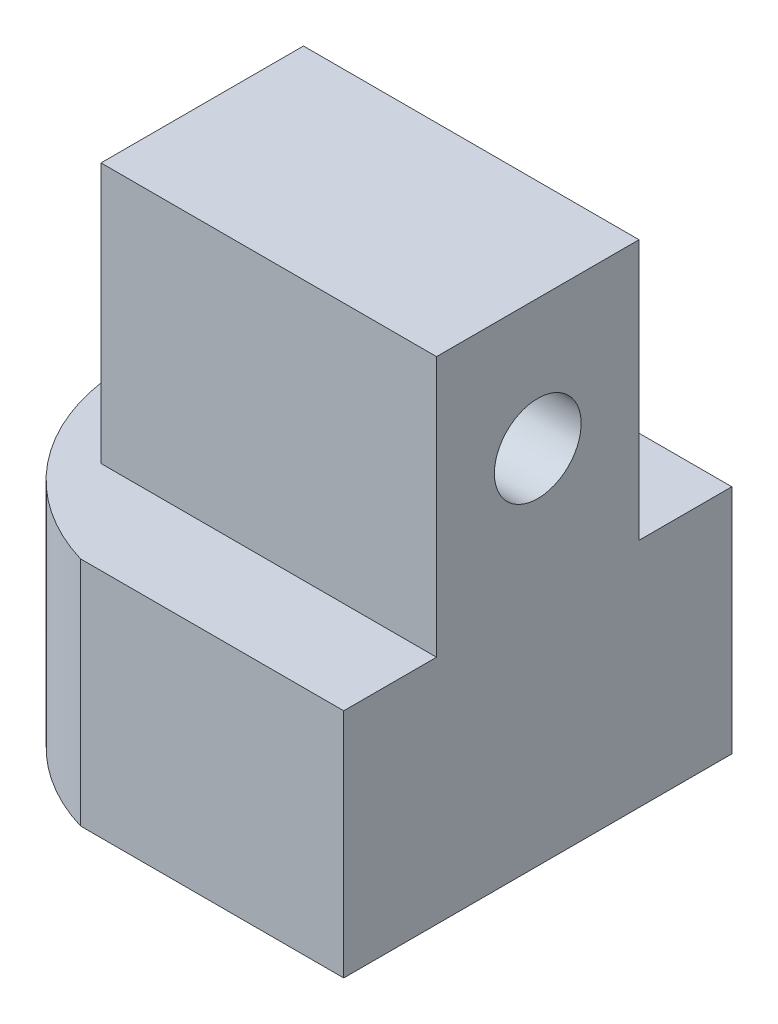
from build123d import *

# Parameters (mm, degrees)
SKETCH1_R           = 7
SKETCH1_R_2         = 4
BOSS_EXTRUDE1_DEPTH = 6
SKETCH2_R           = 7
BOSS_EXTRUDE2_DEPTH = 10
CUT_EXTRUDE1_DEPTH  = 8
SKETCH4_W           = 4.3
SKETCH4_H           = 6.3
CUT_EXTRUDE2_DEPTH  = 6
SKETCH5_OUTSIDE_W   = 21.092
SKETCH5_OUTSIDE_H   = 21.092
CUT_EXTRUDE3_DEPTH  = 8
BOSS_EXTRUDE3_DEPTH = 8
SKETCH9_R           = 7
CUT_EXTRUDE6_DEPTH  = 8
SKETCH10_W          = 9
SKETCH10_H          = 7
BOSS_EXTRUDE5_DEPTH = 9
SKETCH11_W          = 5.3
SKETCH11_H          = 5.3
CUT_EXTRUDE7_DEPTH  = 6
BOSS_EXTRUDE6_DEPTH = 8
SKETCH14_W          = 7
SKETCH14_H          = 9
BOSS_EXTRUDE7_DEPTH = 2.6
SKETCH15_W          = 4
SKETCH15_H          = 5
CUT_EXTRUDE10_DEPTH = 9
SKETCH16_R          = 1.5
CUT_EXTRUDE11_DEPTH = 6.6


with BuildPart() as part:
    # Sketch1 → Boss-Extrude1 (new body)
    with BuildSketch(Plane(origin=(0, 0, 0), x_dir=(1, 0, 0), z_dir=(0, 1, 0))):
        with Locations(Location((0, 0, 0), (0, 0, 270))):  # turned: the seam where the file's is
            Circle(SKETCH1_R)
        with Locations(Location((0, 0, 0), (0, 0, 270))):  # turned: the seam where the file's is
            Circle(SKETCH1_R_2, mode=Mode.SUBTRACT)
    extrude(amount=BOSS_EXTRUDE1_DEPTH)

    # Sketch2 → Boss-Extrude2 (add)
    with BuildSketch(Plane(origin=(0, 6, 0), x_dir=(1, 0, 0), z_dir=(0, 1, 0))):
        with Locations(Location((0, 0, 0), (0, 0, 270))):  # turned: the seam where the file's is
            Circle(SKETCH2_R)
    extrude(amount=BOSS_EXTRUDE2_DEPTH)

    # Sketch3 → Cut-Extrude1 (cut)
    with BuildSketch(Plane(origin=(0, 16, 0), x_dir=(1, 0, 0), z_dir=(0, 1, 0))):
        with BuildLine():
            Line((0, 7), (0, -7))
            ThreePointArc((0, -7), (-7, 0), (0, 7))
        make_face()
    extrude(amount=-CUT_EXTRUDE1_DEPTH, mode=Mode.SUBTRACT)

    # Sketch4 → Cut-Extrude2 (cut)
    with BuildSketch(Plane.ZY):
        with Locations((0, 12.15)):
            Rectangle(SKETCH4_W, SKETCH4_H)
    extrude(amount=-CUT_EXTRUDE2_DEPTH, mode=Mode.SUBTRACT)

    # Sketch5 outside → Cut-Extrude3 (cut)
    with BuildSketch(Plane(origin=(0, 16, 0), x_dir=(1, 0, 0), z_dir=(0, 1, 0))):
        Rectangle(SKETCH5_OUTSIDE_W, SKETCH5_OUTSIDE_H)
        with BuildLine():
            Line((0, 4), (5.744562647, 4))
            ThreePointArc((5.744562647, 4), (7, 0), (5.744562647, -4))
            Line((5.744562647, -4), (0, -4))
            Line((0, -4), (0, 4))
        make_face(mode=Mode.SUBTRACT)
    extrude(amount=-CUT_EXTRUDE3_DEPTH, mode=Mode.SUBTRACT)

    # Sketch7 → Boss-Extrude3 (add)
    with BuildSketch(Plane(origin=(0, 8, 0), x_dir=(1, 0, 0), z_dir=(0, 1, 0))):
        with BuildLine():
            Line((2, 6.708203932), (2, 11.708203932))
            Line((2, 11.708203932), (-2, 11.708203932))
            Line((-2, 11.708203932), (-2, 6.708203932))
            ThreePointArc((-2, 6.708203932), (0, 7), (2, 6.708203932))
        make_face()
        with BuildLine():
            Line((2, -6.708203932), (2, -11.708203932))
            Line((2, -11.708203932), (-2, -11.708203932))
            Line((-2, -11.708203932), (-2, -6.708203932))
            ThreePointArc((-2, -6.708203932), (0, -7), (2, -6.708203932))
        make_face()
    extrude(amount=-BOSS_EXTRUDE3_DEPTH)

    # Sketch9 → Cut-Extrude6 (cut)
    with BuildSketch(Plane(origin=(0, 16, 0), x_dir=(1, 0, 0), z_dir=(0, 1, 0))):
        Circle(SKETCH9_R)
    extrude(amount=-CUT_EXTRUDE6_DEPTH, mode=Mode.SUBTRACT)

    # Sketch10 → Boss-Extrude5 (add)
    with BuildSketch(Plane(origin=(0, 8, 0), x_dir=(1, 0, 0), z_dir=(0, 1, 0))):
        Rectangle(SKETCH10_W, SKETCH10_H)
    extrude(amount=BOSS_EXTRUDE5_DEPTH)

    # Sketch11 → Cut-Extrude7 (cut)
    with BuildSketch(Plane.ZY.offset(4.5)):
        with Locations((0, 12.5)):
            Rectangle(SKETCH11_W, SKETCH11_H)
    extrude(amount=-CUT_EXTRUDE7_DEPTH, mode=Mode.SUBTRACT)

    # Sketch13 → Boss-Extrude6 (add)
    with BuildSketch(Plane(origin=(0, 8, 0), x_dir=(1, 0, 0), z_dir=(0, 1, 0))):
        with BuildLine():
            Line((2, -6.708203932), (7.1, -6.708203932))
            Line((7.1, -6.708203932), (7.1, 6.708203932))
            Line((7.1, 6.708203932), (2, 6.708203932))
            ThreePointArc((2, 6.708203932), (7, 0), (2, -6.708203932))
        make_face()
    extrude(amount=-BOSS_EXTRUDE6_DEPTH)

    # Sketch14 → Boss-Extrude7 (add)
    with BuildSketch(Plane(origin=(4.5, 0, 0), x_dir=(0, 0, -1), z_dir=(1, 0, 0))):
        with Locations((0, 12.5)):
            Rectangle(SKETCH14_W, SKETCH14_H)
    extrude(amount=BOSS_EXTRUDE7_DEPTH)

    # Sketch15 → Cut-Extrude10 (cut, through all)
    with BuildSketch(Plane(origin=(0, 8, 0), x_dir=(1, 0, 0), z_dir=(0, 1, 0))):
        with Locations((0, 9.208203932)):
            Rectangle(SKETCH15_W, SKETCH15_H)
        with Locations((0, -9.208203932)):
            Rectangle(SKETCH15_W, SKETCH15_H)
    extrude(amount=-CUT_EXTRUDE10_DEPTH, mode=Mode.SUBTRACT)

    # Sketch16 → Cut-Extrude11 (cut, through all)
    with BuildSketch(Plane.ZY.offset(-1.5)):
        with Locations((0, 12.5)):
            Circle(SKETCH16_R)
    extrude(amount=-CUT_EXTRUDE11_DEPTH, mode=Mode.SUBTRACT)


solid = part.part
